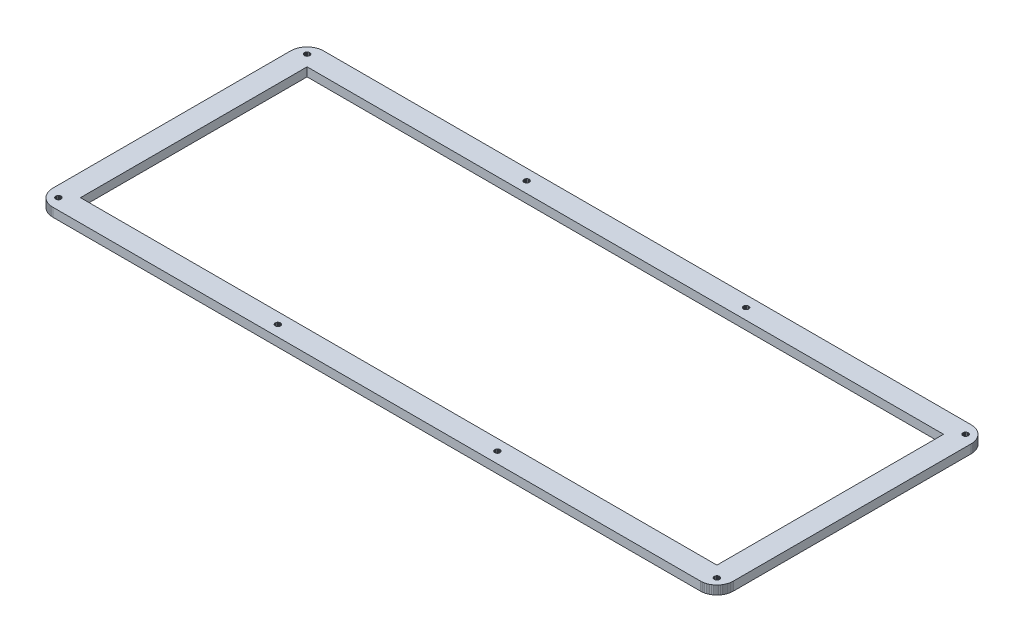
from build123d import *

# Parameters (mm, degrees)
SKETCH1_W           = 347.6143
SKETCH1_H           = 123.7785
BOSS_EXTRUDE1_DEPTH = 4.7625


with BuildPart() as part:
    # Sketch1 → Boss-Extrude1 (new body)
    with BuildSketch(Plane(origin=(0, 0, 0), x_dir=(1, 0, 0), z_dir=(0, 1, 0))):
        Polygon((362.807, 147.967), (363.513, 147.941), (364.215, 147.857), (364.91, 147.719), (365.591, 147.527), (366.254, 147.282), (366.896, 146.987), (367.51, 146.641), (368.099, 146.25), (368.653, 145.812), (369.171, 145.331), (369.651, 144.812), (370.089, 144.259), (370.48, 143.67), (370.826, 143.053), (371.122, 142.412), (371.369, 141.749), (371.56, 141.07), (371.697, 140.375), (371.778, 139.674), (371.807, 138.967), (371.807, 9.09091), (371.778, 8.38535), (371.697, 7.68396), (371.56, 6.99079), (371.369, 6.31003), (371.122, 5.6472), (370.826, 5.00641), (370.48, 4.38905), (370.089, 3.80062), (369.651, 3.24666), (369.171, 2.72852), (368.653, 2.24758), (368.099, 1.81074), (367.51, 1.418), (366.896, 1.07211), (366.254, 0.777215), (365.591, 0.531922), (364.91, 0.340376), (364.215, 0.202572), (363.513, 0.118511), (362.807, 0.0909507), (9.09507, 0.0909507), (8.3881, 0.118511), (7.68671, 0.202572), (6.99216, 0.340376), (6.31278, 0.531922), (5.64995, 0.777215), (5.00916, 1.07211), (4.3918, 1.418), (3.8034, 1.81074), (3.24942, 2.24758), (2.73127, 2.72852), (2.25034, 3.24666), (1.81212, 3.80062), (1.42076, 4.38905), (1.07487, 5.00641), (0.77997, 5.6472), (0.534681, 6.31003), (0.343131, 6.99079), (0.205328, 7.68396), (0.121267, 8.38535), (0.0937066, 9.09228), (0.0950846, 138.967), (0.121267, 139.674), (0.205328, 140.375), (0.343131, 141.07), (0.534681, 141.749), (0.77997, 142.412), (1.07487, 143.053), (1.42076, 143.67), (1.81212, 144.259), (2.25034, 144.812), (2.73127, 145.331), (3.24942, 145.812), (3.8034, 146.25), (4.3918, 146.641), (5.00916, 146.987), (5.64995, 147.282), (6.31278, 147.527), (6.99216, 147.719), (7.68671, 147.857), (8.3881, 147.941), (9.09507, 147.968), align=None)
        Polygon((365.326, 7.51858), (364.917, 7.31188), (364.589, 6.98253), (364.381, 6.57186), (364.307, 6.11572), (364.381, 5.66099), (364.589, 5.25032), (364.917, 4.92372), (365.326, 4.71428), (365.781, 4.64125), (366.24, 4.71428), (366.649, 4.92372), (366.977, 5.25032), (367.185, 5.66099), (367.259, 6.11572), (367.185, 6.57186), (366.977, 6.98253), (366.649, 7.31188), (366.24, 7.51858), (365.781, 7.5916), align=None, mode=Mode.SUBTRACT)
        Polygon((245.438, 7.51858), (245.027, 7.31188), (244.703, 6.98253), (244.492, 6.57186), (244.42, 6.11572), (244.492, 5.66099), (244.703, 5.25032), (245.027, 4.92372), (245.438, 4.71428), (245.894, 4.64125), (246.35, 4.71428), (246.761, 4.92372), (247.088, 5.25032), (247.297, 5.66099), (247.37, 6.11572), (247.297, 6.57186), (247.088, 6.98253), (246.761, 7.31188), (246.35, 7.51858), (245.894, 7.5916), align=None, mode=Mode.SUBTRACT)
        Polygon((125.552, 7.51858), (125.138, 7.31188), (124.815, 6.98253), (124.604, 6.57186), (124.532, 6.11572), (124.604, 5.66099), (124.815, 5.25032), (125.138, 4.92372), (125.552, 4.71428), (126.007, 4.64125), (126.463, 4.71428), (126.873, 4.92372), (127.201, 5.25032), (127.409, 5.66099), (127.482, 6.11572), (127.409, 6.57186), (127.201, 6.98253), (126.873, 7.31188), (126.463, 7.51858), (126.007, 7.5916), align=None, mode=Mode.SUBTRACT)
        Polygon((5.66374, 7.51858), (5.25307, 7.31188), (4.9251, 6.98253), (4.71703, 6.57186), (4.644, 6.11572), (4.71703, 5.66099), (4.9251, 5.25032), (5.25307, 4.92372), (5.66374, 4.71428), (6.11851, 4.64125), (6.57461, 4.71428), (6.98528, 4.92372), (7.31326, 5.25032), (7.52133, 5.66099), (7.59435, 6.11572), (7.52133, 6.57186), (7.31326, 6.98253), (6.98528, 7.31188), (6.57461, 7.51858), (6.11851, 7.5916), align=None, mode=Mode.SUBTRACT)
        with Locations((185.95185, 74.02975)):
            Rectangle(SKETCH1_W, SKETCH1_H, mode=Mode.SUBTRACT)
        Polygon((125.552, 143.345), (125.138, 143.137), (124.815, 142.809), (124.604, 142.398), (124.532, 141.942), (124.604, 141.487), (124.815, 141.077), (125.138, 140.75), (125.552, 140.541), (126.007, 140.468), (126.463, 140.541), (126.873, 140.75), (127.201, 141.077), (127.409, 141.487), (127.482, 141.942), (127.409, 142.398), (127.201, 142.809), (126.873, 143.137), (126.463, 143.345), (126.007, 143.417), align=None, mode=Mode.SUBTRACT)
        Polygon((245.438, 143.345), (245.027, 143.137), (244.703, 142.809), (244.492, 142.398), (244.42, 141.942), (244.492, 141.487), (244.703, 141.077), (245.027, 140.75), (245.438, 140.541), (245.894, 140.468), (246.35, 140.541), (246.761, 140.75), (247.088, 141.077), (247.297, 141.487), (247.37, 141.942), (247.297, 142.398), (247.088, 142.809), (246.761, 143.137), (246.35, 143.345), (245.894, 143.417), align=None, mode=Mode.SUBTRACT)
        Polygon((365.326, 143.345), (364.917, 143.137), (364.589, 142.809), (364.381, 142.398), (364.307, 141.942), (364.381, 141.487), (364.589, 141.077), (364.917, 140.75), (365.326, 140.541), (365.781, 140.468), (366.24, 140.541), (366.649, 140.75), (366.977, 141.077), (367.185, 141.487), (367.259, 141.942), (367.185, 142.398), (366.977, 142.809), (366.649, 143.137), (366.24, 143.345), (365.781, 143.417), align=None, mode=Mode.SUBTRACT)
        Polygon((5.66374, 143.345), (5.25307, 143.137), (4.9251, 142.809), (4.71703, 142.398), (4.644, 141.942), (4.71703, 141.487), (4.9251, 141.077), (5.25307, 140.75), (5.66374, 140.541), (6.11851, 140.468), (6.57461, 140.541), (6.98528, 140.75), (7.31326, 141.077), (7.52133, 141.487), (7.59435, 141.942), (7.52133, 142.398), (7.31326, 142.809), (6.98528, 143.137), (6.57461, 143.345), (6.11851, 143.417), align=None, mode=Mode.SUBTRACT)
    extrude(amount=BOSS_EXTRUDE1_DEPTH)


solid = part.part
